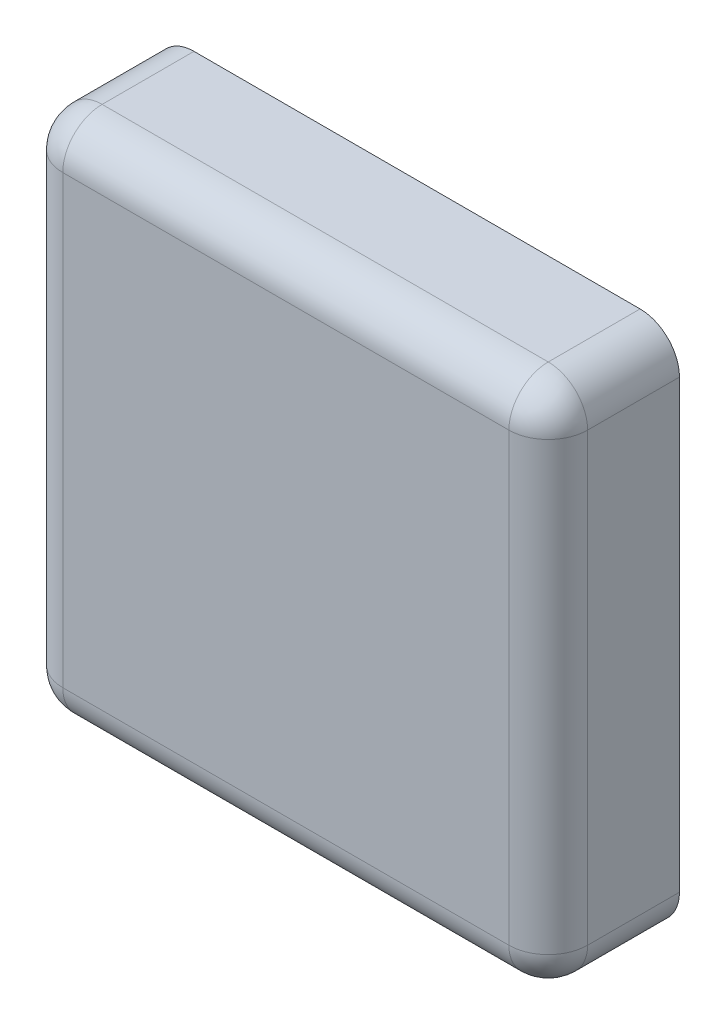
from build123d import *

# Parameters (mm, degrees)
SKETCH1_W           = 40
SKETCH1_H           = 40
BOSS_EXTRUDE1_DEPTH = 5
FILLET1_R           = 3


with BuildPart() as part:
    # Sketch1 → Boss-Extrude1 (new body, symmetric)
    with BuildSketch(Plane.XY):
        with Locations((-20, 20)):
            Rectangle(SKETCH1_W, SKETCH1_H)
    extrude(amount=BOSS_EXTRUDE1_DEPTH, both=True)

    # Fillet1
    fillet1_edges = [part.edges().sort_by_distance(p)[0] for p in [
        (-40, 20, 5),
        (-20, 0, 5),
        (0, 20, 5),
        (0, 0, 0),
        (-40, 0, 0),
        (-40, 40, 0),
        (0, 40, 0),
        (-20, 40, 5),
    ]]
    fillet(fillet1_edges, radius=FILLET1_R)


solid = part.part
